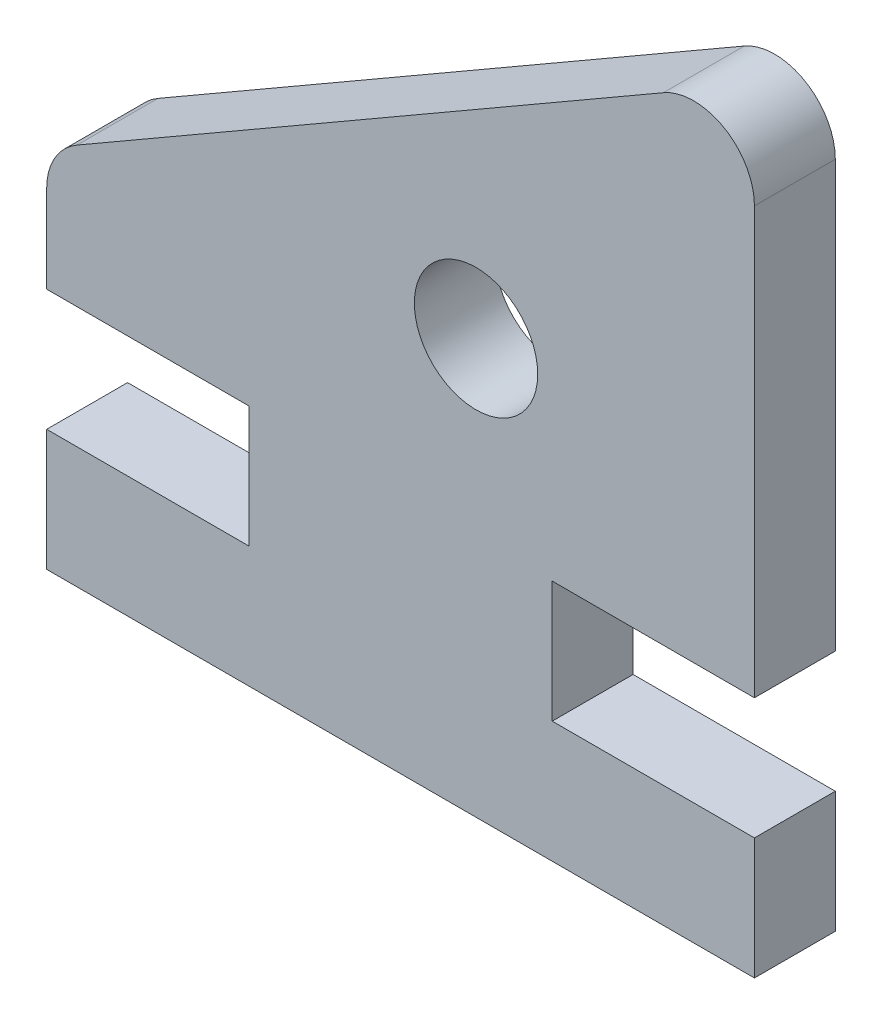
from build123d import *

# Parameters (mm, degrees)
ESBO_O1_R                = 3.05
RESSALTO_EXTRUS_O1_DEPTH = 4
FILETE1_R                = 3


with BuildPart() as part:
    # Esboço1 → Ressalto-extrusão1 (new body)
    with BuildSketch(Plane.XY):
        Polygon((0, 38.263883749), (-35, 18.056624327), (-35, 12), (-25, 12), (-25, 6), (-35, 6), (-35, 0), (0, 0), (0, 6), (-10, 6), (-10, 12), (0, 12), align=None)
        with Locations((-13.767949192, 20.5)):
            Circle(ESBO_O1_R, mode=Mode.SUBTRACT)
    extrude(amount=RESSALTO_EXTRUS_O1_DEPTH)

    # Filete1
    filete1_edges = [part.edges().sort_by_distance(p)[0] for p in [
        (-35, 18.056624327, 2),
        (0, 38.263883749, 2),
    ]]
    fillet(filete1_edges, radius=FILETE1_R)


solid = part.part
